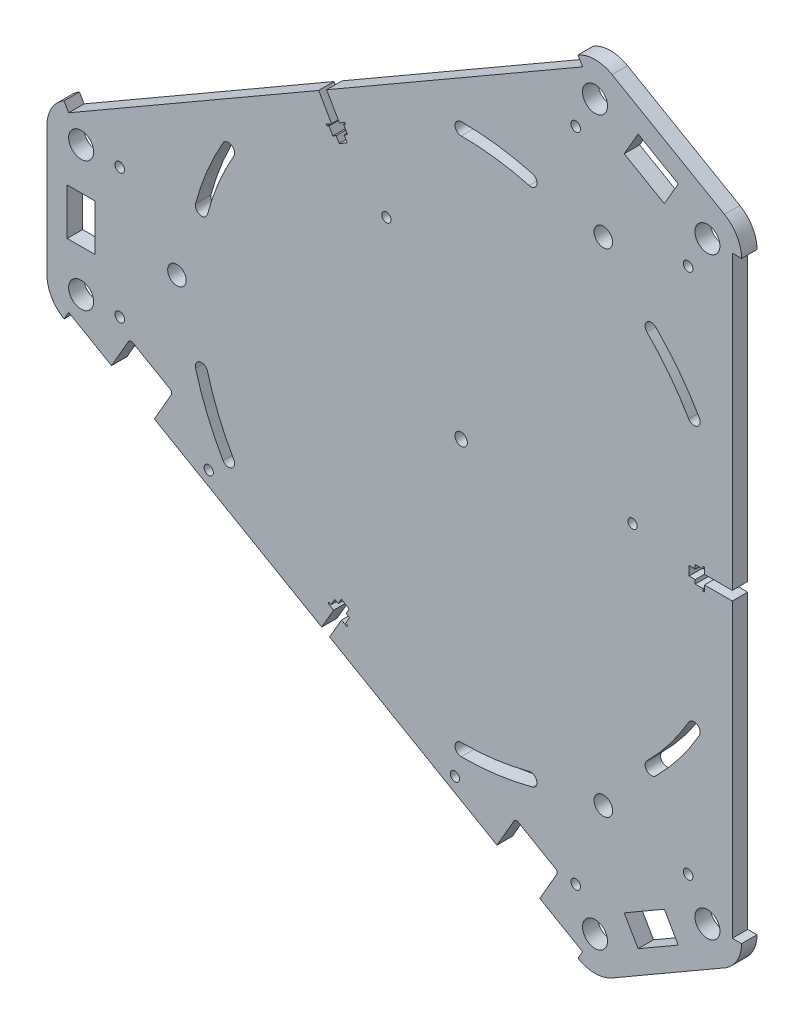
from build123d import *

# Parameters (mm, degrees)
SKETCH1_R           = 4.05
SKETCH1_R_2         = 1.55
SKETCH1_R_3         = 2
SKETCH1_R_4         = 3
SKETCH1_W           = 9
SKETCH1_H           = 15
BOSS_EXTRUDE1_DEPTH = 5
CUT_EXTRUDE1_DEPTH  = 186.463215446
SKETCH3_R           = 1.5
CUT_EXTRUDE2_DEPTH  = 186.463215446
CUT_EXTRUDE4_DEPTH  = 186.463215446
CIRPATTERN1_COUNT   = 3


with BuildPart() as part:
    # Sketch1 → Boss-Extrude1 (new body)
    with BuildSketch(Plane.XY):
        with BuildLine():
            Line((-127.025, 27.9715045), (39.288466521, 123.992629166))
            Line((39.288466521, 123.992629166), (37.788477193, 126.590686893))
            ThreePointArc((37.788477193, 126.590686893), (43.313466521, 128.071103321), (48.838455849, 126.590686893))
            Line((48.838455849, 126.590686893), (85.211522807, 105.590686893))
            ThreePointArc((85.211522807, 105.590686893), (89.256095707, 101.546113993), (90.736512135, 96.021124665))
            Line((90.736512135, 96.021124665), (87.736533479, 96.021124665))
            Line((87.736533479, 96.021124665), (87.736533479, -96.021124665))
            Line((87.736533479, -96.021124665), (90.736512135, -96.021124665))
            ThreePointArc((90.736512135, -96.021124665), (89.394693991, -101.298780185), (85.695118183, -105.29468591))
            Line((85.695118183, -105.29468591), (48.841497032, -126.58893042))
            ThreePointArc((48.841497032, -126.58893042), (43.315221896, -128.071103182), (37.788476129, -126.590686279))
            Line((37.788476129, -126.590686279), (39.288465746, -123.992628719))
            Line((39.288465746, -123.992628719), (-127.024990103, -27.971485569))
            Line((-127.024990103, -27.971485569), (-128.524990392, -30.569561613))
            ThreePointArc((-128.524990392, -30.569561613), (-132.569562534, -26.524988796), (-134.049978656, -21))
            Line((-134.049978656, -21), (-134.049978656, 21))
            ThreePointArc((-134.049978656, 21), (-132.569562227, 26.524989328), (-128.524989328, 30.569562227))
            Line((-128.524989328, 30.569562227), (-127.025, 27.9715045))
        make_face()
        with Locations((-123, 21)):
            Circle(SKETCH1_R, mode=Mode.SUBTRACT)
        with Locations((-123, -21)):
            Circle(SKETCH1_R, mode=Mode.SUBTRACT)
        with Locations((43.313466521, 117.021124665)):
            Circle(SKETCH1_R, mode=Mode.SUBTRACT)
        with Locations((79.686533479, 96.021124665)):
            Circle(SKETCH1_R, mode=Mode.SUBTRACT)
        with Locations((79.686533479, -96.021124665)):
            Circle(SKETCH1_R, mode=Mode.SUBTRACT)
        with Locations((43.313466521, -117.021124665)):
            Circle(SKETCH1_R, mode=Mode.SUBTRACT)
        with Locations((-110.5, 21)):
            Circle(SKETCH1_R_2, mode=Mode.SUBTRACT)
        with Locations((-110.5, -21)):
            Circle(SKETCH1_R_2, mode=Mode.SUBTRACT)
        with Locations((73.436533479, 85.195807118)):
            Circle(SKETCH1_R_2, mode=Mode.SUBTRACT)
        with Locations((37.063466521, 106.195807118)):
            Circle(SKETCH1_R_2, mode=Mode.SUBTRACT)
        with Locations((37.063466521, -106.195807118)):
            Circle(SKETCH1_R_2, mode=Mode.SUBTRACT)
        with Locations((73.436533479, -85.195807118)):
            Circle(SKETCH1_R_2, mode=Mode.SUBTRACT)
        Circle(SKETCH1_R_3, mode=Mode.SUBTRACT)
        with Locations((-92, 0)):
            Circle(SKETCH1_R_4, mode=Mode.SUBTRACT)
        with Locations((46, 79.674337148)):
            Circle(SKETCH1_R_4, mode=Mode.SUBTRACT)
        with Locations((46, -79.674337148)):
            Circle(SKETCH1_R_4, mode=Mode.SUBTRACT)
        Polygon((70.245190528, 106.668238983), (65.745190528, 98.874010348), (52.754809472, 106.374010348), (57.254809472, 114.168238983), align=None, mode=Mode.SUBTRACT)
        with Locations((-123, 0)):
            Rectangle(SKETCH1_W, SKETCH1_H, mode=Mode.SUBTRACT)
        Polygon((57.254809472, -114.168238983), (52.754809472, -106.374010348), (65.745190528, -98.874010348), (70.245190528, -106.668238983), align=None, mode=Mode.SUBTRACT)
    extrude(amount=BOSS_EXTRUDE1_DEPTH)

    # Sketch2 → Cut-Extrude1 (cut, through all)
    with BuildSketch(Plane.XY.offset(5)):
        Polygon((87.736533479, 1.48), (78.736533479, 1.48), (78.736533479, 3.5), (78.236533479, 3.5), (78.236533479, 2.75), (75.736533479, 2.75), (75.736533479, 1.48), (73.736533479, 1.48), (73.736533479, -1.48), (75.736533479, -1.48), (75.736533479, -2.75), (78.236533479, -2.75), (78.236533479, -3.5), (78.736533479, -3.5), (78.736533479, -1.48), (87.736533479, -1.48), align=None)
        Polygon((-43.236068195, -77.847066833), (-38.736068195, -70.052838199), (-36.986696879, -71.062838199), (-36.736696879, -70.629825497), (-37.386215932, -70.254825497), (-36.136215932, -68.089761988), (-37.236068195, -67.454761988), (-36.236068195, -65.72271118), (-38.79950339, -64.24271118), (-39.79950339, -65.974761988), (-40.899355653, -65.339761988), (-42.149355653, -67.504825497), (-42.798874706, -67.129825497), (-43.048874706, -67.562838199), (-41.29950339, -68.572838199), (-45.79950339, -76.367066833), align=None)
        Polygon((-46.449022443, 75.242066833), (-41.949022443, 67.447838199), (-43.698393759, 66.437838199), (-43.448393759, 66.004825497), (-42.798874706, 66.379825497), (-41.548874706, 64.214761988), (-40.449022443, 64.849761988), (-39.449022443, 63.11771118), (-36.885587248, 64.59771118), (-37.885587248, 66.329761988), (-36.785734985, 66.964761988), (-38.035734985, 69.129825497), (-37.386215932, 69.504825497), (-37.636215932, 69.937838199), (-39.385587248, 68.927838199), (-43.885587248, 76.722066833), align=None)
    extrude(amount=-CUT_EXTRUDE1_DEPTH, mode=Mode.SUBTRACT)

    # Sketch3 → Cut-Extrude2 (cut, through all)
    with BuildSketch(Plane.XY.offset(5)):
        with Locations((-81.705432956, -49.517948353)):
            Circle(SKETCH3_R)
        with Locations((-2.03110092, -95.517957208)):
            Circle(SKETCH3_R)
        with Locations((55.468910149, 4.074957836)):
            Circle(SKETCH3_R)
        with Locations((-24.205421887, 50.074966692)):
            Circle(SKETCH3_R)
        with BuildLine():
            Line((-112.802559279, -37.337512553), (-100.678204404, -44.337513901))
            ThreePointArc((-100.678204404, -44.337513901), (-99.91938537, -44.437414408), (-99.31217896, -43.971488649))
            Line((-99.31217896, -43.971488649), (-93.812177901, -34.445209818))
            ThreePointArc((-93.812177901, -34.445209818), (-93.712277394, -33.686390784), (-94.178203153, -33.079184374))
            Line((-94.178203153, -33.079184374), (-106.302558028, -26.079183026))
            ThreePointArc((-106.302558028, -26.079183026), (-107.061377062, -25.97928252), (-107.668583473, -26.445208278))
            Line((-107.668583473, -26.445208278), (-113.168584531, -35.971487109))
            ThreePointArc((-113.168584531, -35.971487109), (-113.268485038, -36.730306143), (-112.802559279, -37.337512553))
        make_face()
        with BuildLine():
            Line((25.432070618, -115.992612669), (30.932069559, -106.466332616))
            ThreePointArc((30.932069559, -106.466332616), (31.031969897, -105.70751356), (30.566044003, -105.100307253))
            Line((30.566044003, -105.100307253), (18.441687572, -98.1003086))
            ThreePointArc((18.441687572, -98.1003086), (17.682868516, -98.000408262), (17.075662209, -98.466334156))
            Line((17.075662209, -98.466334156), (11.575663268, -107.992614209))
            ThreePointArc((11.575663268, -107.992614209), (11.47576293, -108.751433265), (11.941688824, -109.358639572))
            Line((11.941688824, -109.358639572), (24.066045255, -116.358638224))
            ThreePointArc((24.066045255, -116.358638224), (24.824864311, -116.458538563), (25.432070618, -115.992612669))
        make_face()
    extrude(amount=-CUT_EXTRUDE2_DEPTH, mode=Mode.SUBTRACT)

    # Sketch6 → Cut-Extrude4 (cut, through all)
    with BuildSketch(Plane.XY.offset(5)):
        with BuildLine():
            ThreePointArc((-77.076260937, 44.5), (-82.225278394, 34.05882548), (-85.96739854, 23.034895014))
            ThreePointArc((-85.96739854, 23.034895014), (-84.553184977, 20.585405271), (-82.103695235, 21.999618834))
            ThreePointArc((-82.103695235, 21.999618834), (-78.529760263, 32.528091751), (-73.612159322, 42.5))
            ThreePointArc((-73.612159322, 42.5), (-74.344210129, 45.232050808), (-77.076260937, 44.5))
        make_face()
        with BuildLine():
            ThreePointArc((-73.612159322, -42.5), (-74.344210129, -45.232050808), (-77.076260937, -44.5))
            ThreePointArc((-77.076260937, -44.5), (-82.225278394, -34.05882548), (-85.96739854, -23.034895014))
            ThreePointArc((-85.96739854, -23.034895014), (-84.553184977, -20.585405271), (-82.103695235, -21.999618834))
            ThreePointArc((-82.103695235, -21.999618834), (-78.529760263, -32.528091751), (-73.612159322, -42.5))
        make_face()
    cut_extrude4 = extrude(amount=-CUT_EXTRUDE4_DEPTH, mode=Mode.SUBTRACT)

    # CirPattern1: Cut-Extrude4 ×3 about axis
    cirpattern1_axis = Axis((0, 0, 5), (0, 0, -1))
    for i in range(1, CIRPATTERN1_COUNT):
        add(cut_extrude4.rotate(cirpattern1_axis, i * 360 / CIRPATTERN1_COUNT), mode=Mode.SUBTRACT)


solid = part.part
